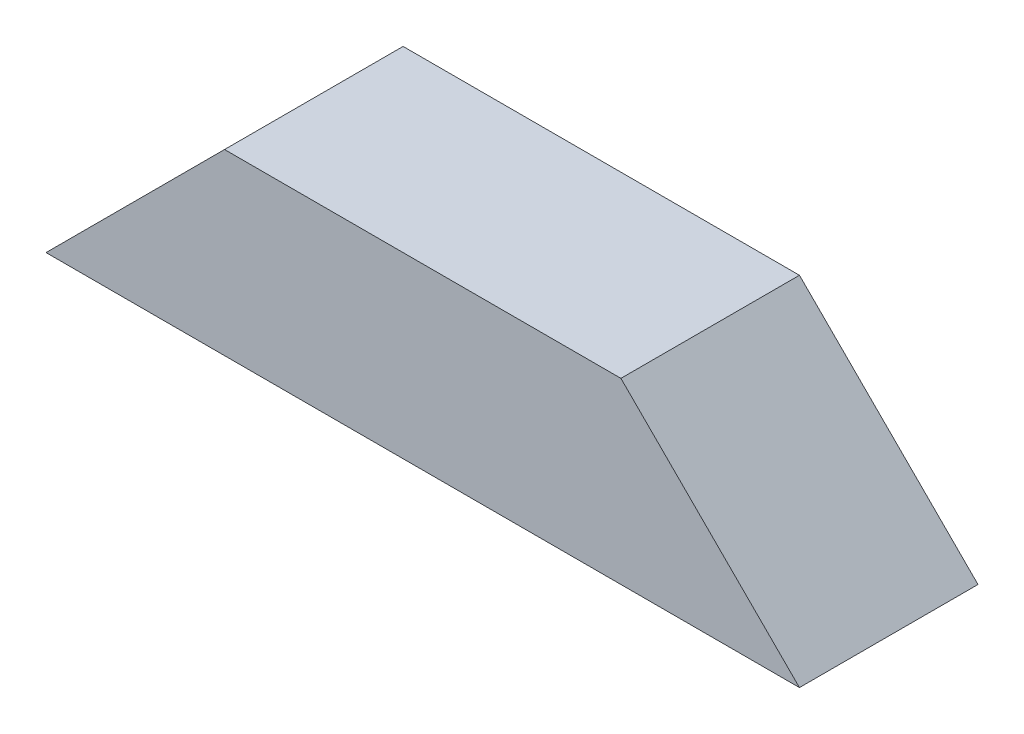
from build123d import *

# Parameters (mm, degrees)
EXTRUDE_1_DEPTH = 5


with BuildPart() as part:
    # 草图1 → 凸台-拉伸1 (new body)
    with BuildSketch(Plane.XY):
        Polygon((19.221766901, 24.961051909), (40.321766901, 24.961051909), (35.321766901, 29.961051909), (24.221766901, 29.961051909), align=None)
    extrude(amount=EXTRUDE_1_DEPTH)


solid = part.part
